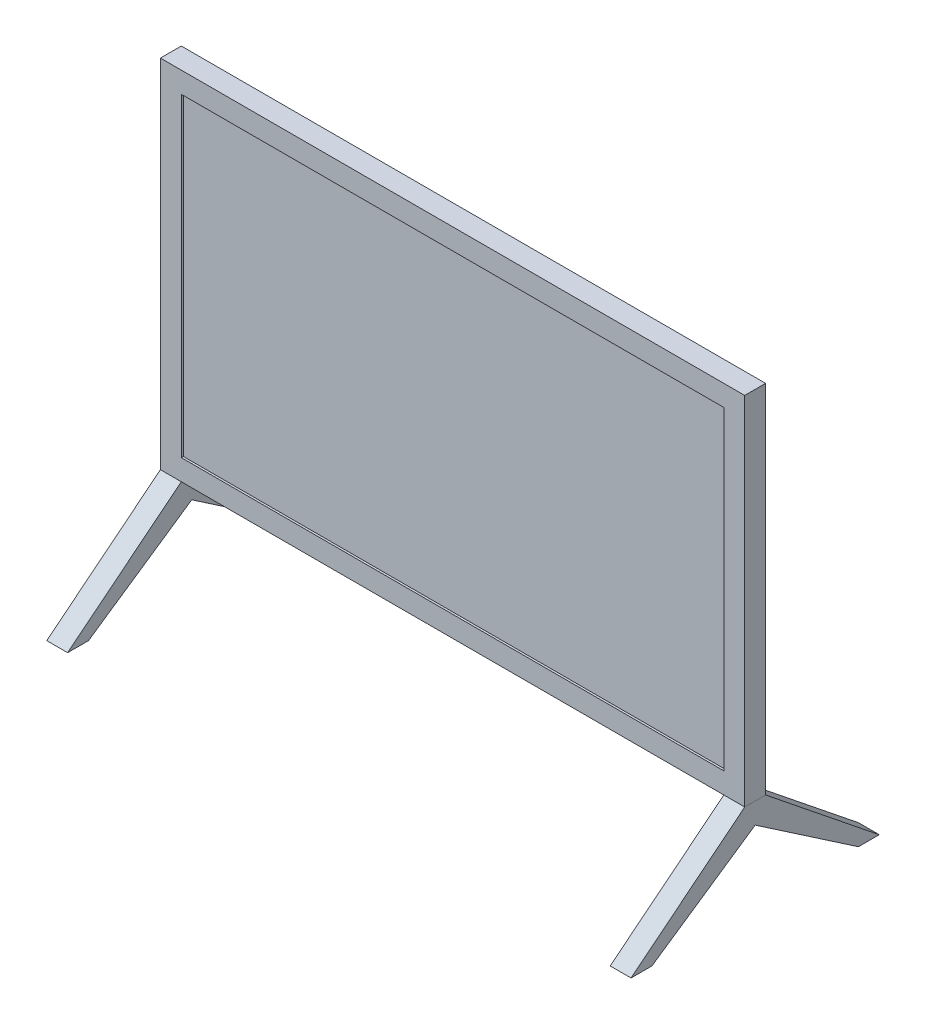
from build123d import *

# Parameters (mm, degrees)
ESQUISSE1_W        = 568
ESQUISSE1_H        = 346.513925803
ESQUISSE1_W_2      = 527.4
ESQUISSE1_H_2      = 305.913925803
BOSS_EXTRU_1_DEPTH = 20.3
BOSS_EXTRU_2_REACH = 328.214
ESQUISSE2_W        = 527.4
ESQUISSE2_H        = 18.3
BOSS_EXTRU_3_DEPTH = 20.3


with BuildPart() as part:
    # Esquisse1 → Boss.-Extru.1 (new body)
    with BuildSketch(Plane.XY):
        with Locations((-263.7, 152.956962901)):
            Rectangle(ESQUISSE1_W, ESQUISSE1_H)
        with Locations((-263.7, 152.956962902)):
            Rectangle(ESQUISSE1_W_2, ESQUISSE1_H_2, mode=Mode.SUBTRACT)
    extrude(amount=BOSS_EXTRU_1_DEPTH)

    # Esquisse2 → Boss.-Extru.2 (add, up to next)
    with BuildSketch(Plane(origin=(0, 0, 0), x_dir=(1, 0, 0), z_dir=(0, 1, 0)), mode=Mode.PRIVATE) as boss_extru_2_sk1:
        with Locations((-263.7, -9.15)):
            Rectangle(ESQUISSE2_W, ESQUISSE2_H)
    boss_extru_2_tool1 = extrude(boss_extru_2_sk1.sketch, amount=BOSS_EXTRU_2_REACH, mode=Mode.PRIVATE) - part.part
    add(boss_extru_2_tool1.solids().sort_by_distance((-263.7, 0, 9.15))[0])


with BuildPart() as body_2:
    # Esquisse3 → Boss.-Extru.3 (new body)
    with BuildSketch(Plane.ZY.offset(547.7)):
        Polygon((10.15, -40.6), (10.15, -20.3), (0, -20.3), (-110.486746728, -108.986074197), (-90.186746728, -108.986074197), align=None)
        Polygon((20.3, -20.3), (10.15, -20.3), (10.15, -40.6), (110.486746728, -108.986074197), (130.786746728, -108.986074197), align=None)
    extrude(amount=-BOSS_EXTRU_3_DEPTH)


with BuildPart() as body_3:
    # Symétrie2: mirrored copy
    add(body_2.part.mirror(Plane.ZY.offset(263.7)))


solid = Compound([part.part, body_2.part, body_3.part])
